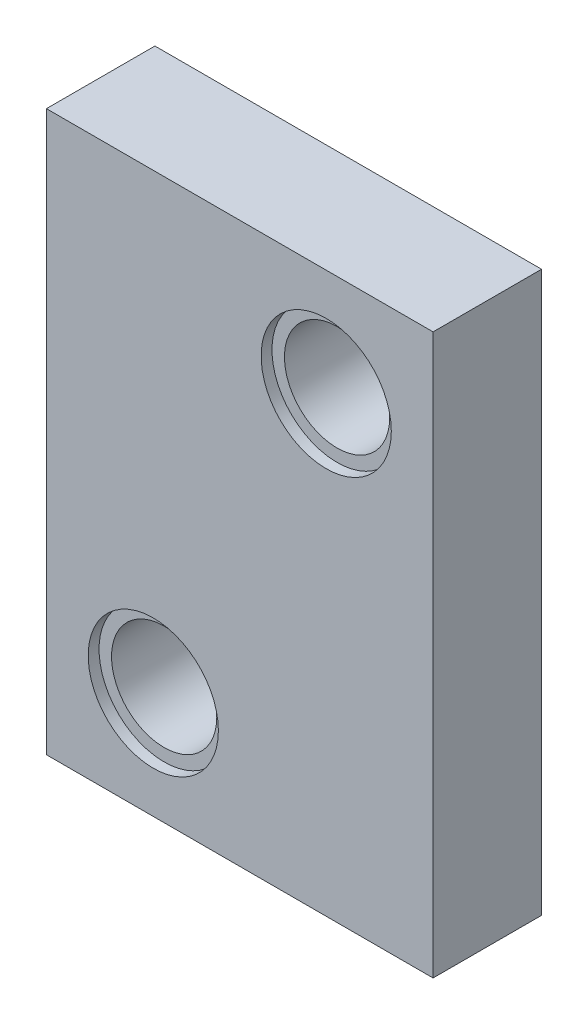
from build123d import *

# Parameters (mm, degrees)
SKETCH1_W           = 17.82
SKETCH1_H           = 25.79
BOSS_EXTRUDE2_DEPTH = 5
SKETCH2_R           = 2.425
CUT_EXTRUDE1_DEPTH  = 15
SKETCH3_R           = 3
CUT_EXTRUDE2_DEPTH  = 0.5


with BuildPart() as part:
    # Sketch1 → Boss-Extrude2 (new body)
    with BuildSketch(Plane.XY):
        with Locations((8.91, 12.895)):
            Rectangle(SKETCH1_W, SKETCH1_H)
    extrude(amount=BOSS_EXTRUDE2_DEPTH)

    # Sketch2 → Cut-Extrude1 (cut)
    with BuildSketch(Plane.XY.offset(5)):
        with Locations((4.925, 4.925)):
            Circle(SKETCH2_R)
        with Locations((12.895, 20.865)):
            Circle(SKETCH2_R)
    extrude(amount=-CUT_EXTRUDE1_DEPTH, mode=Mode.SUBTRACT)

    # Sketch3 → Cut-Extrude2 (cut)
    with BuildSketch(Plane.XY.offset(5)):
        with Locations((4.925, 4.925)):
            Circle(SKETCH3_R)
        with Locations((12.895, 20.865)):
            Circle(SKETCH3_R)
    extrude(amount=-CUT_EXTRUDE2_DEPTH, mode=Mode.SUBTRACT)


solid = part.part
